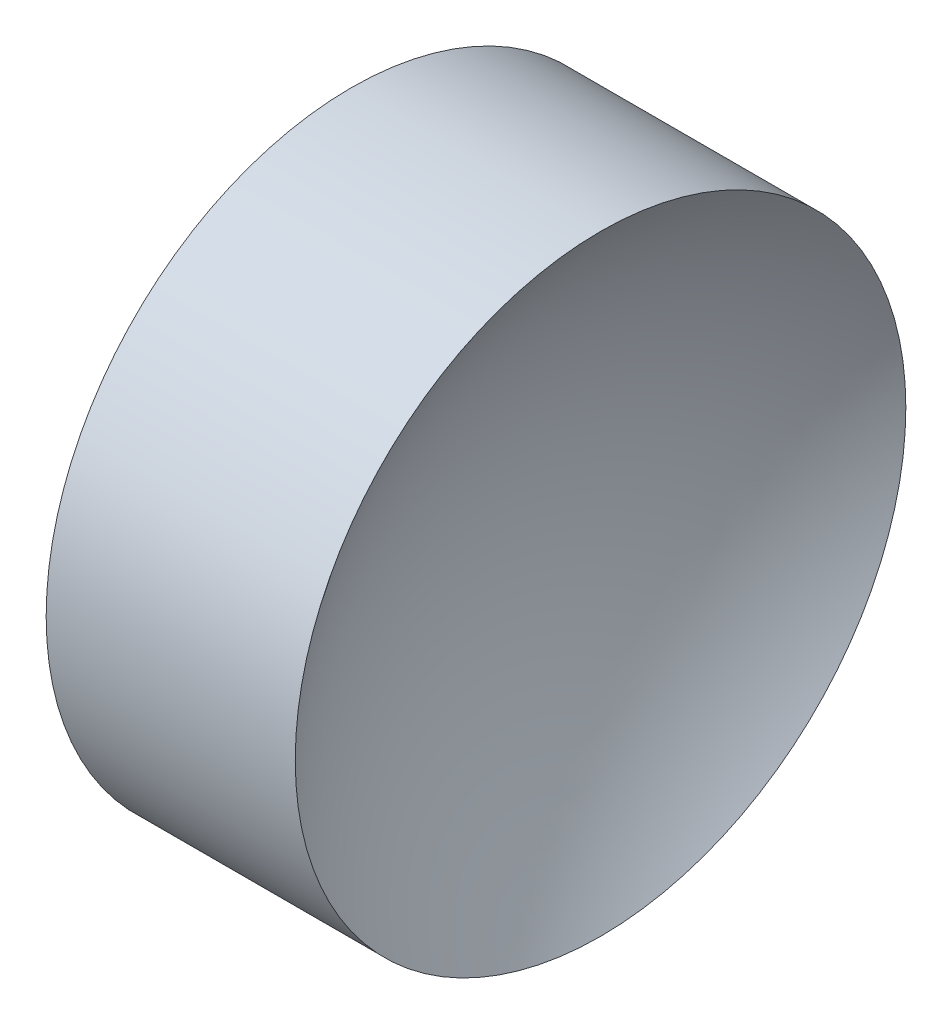
from build123d import *


with BuildPart() as part:
    # 草图1 → 旋转1 (revolve)
    with BuildSketch(Plane.XY, mode=Mode.PRIVATE) as revolve_1_sk:
        with BuildLine():
            Line((22.172189475, 13.044520575), (22.172189475, 16.194520575))
            Line((22.172189475, 16.194520575), (24.742189475, 16.194520575))
            ThreePointArc((24.742189475, 16.194520575), (23.946986815, 14.707906454), (23.672184647, 13.044520575))
            Line((23.672184647, 13.044520575), (22.172189475, 13.044520575))
        make_face()
    revolve(revolve_1_sk.sketch.rotate(Axis((21.224930557, 13.044520575, 0), (1, 0, 0)), 180), axis=Axis((21.224930557, 13.044520575, 0), (1, 0, 0)))  # turned: the seam where the file's is


solid = part.part
